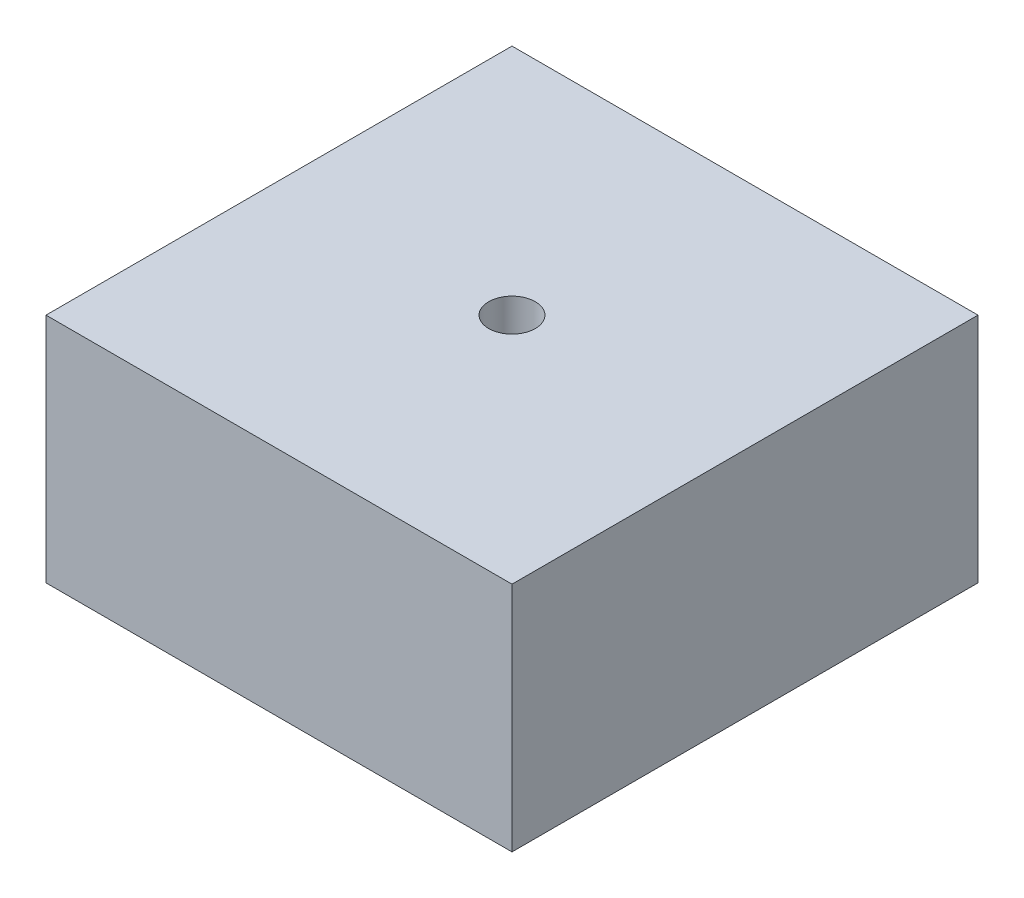
from build123d import *

# Parameters (mm, degrees)
SKETCH1_W           = 100
SKETCH1_H           = 100
BOSS_EXTRUDE1_DEPTH = 49.7625
SKETCH2_R           = 5
CUT_EXTRUDE1_DEPTH  = 50.7625


with BuildPart() as part:
    # Sketch1 → Boss-Extrude1 (new body)
    with BuildSketch(Plane(origin=(0, 0, 0), x_dir=(1, 0, 0), z_dir=(0, 1, 0))):
        Rectangle(SKETCH1_W, SKETCH1_H)
    extrude(amount=BOSS_EXTRUDE1_DEPTH)

    # Sketch2 → Cut-Extrude1 (cut, through all)
    with BuildSketch(Plane(origin=(0, 49.7625, 0), x_dir=(-1, 0, 0), z_dir=(0, 1, 0))):
        Circle(SKETCH2_R)
    extrude(amount=-CUT_EXTRUDE1_DEPTH, mode=Mode.SUBTRACT)


solid = part.part
